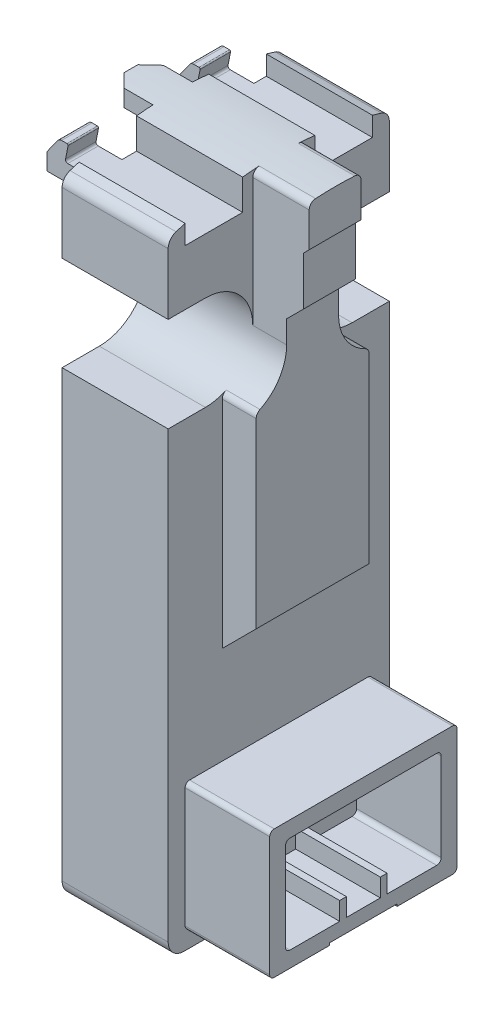
from build123d import *

# Parameters (mm, degrees)
BOSS_EXTRUDE1_DEPTH      = 8.45
SKETCH2_W                = 12
SKETCH2_H                = 30
CUT_EXTRUDE1_DEPTH       = 8.45
CUT_EXTRUDE2_DEPTH       = 8.45
SKETCH4_W                = 0.8
SKETCH4_H                = 1.9
CUT_EXTRUDE3_DEPTH       = 8.45
SKETCH5_W                = 0.8
SKETCH5_H                = 1.9
CUT_EXTRUDE4_DEPTH       = 8.45
BOSS_EXTRUDE2_DEPTH      = 2.5
CUT_EXTRUDE5_DEPTH       = 3
CUT_EXTRUDE5_DEPTH_BACK  = 3
CUT_EXTRUDE6_DEPTH       = 5
CUT_EXTRUDE6_DEPTH_BACK  = 5
SKETCH9_W                = 8.3
SKETCH9_H                = 18.5
CUT_EXTRUDE7_DEPTH       = 3
BOSS_EXTRUDE3_DEPTH      = 3.6
BOSS_EXTRUDE3_DEPTH_BACK = 3.6
SKETCH11_W               = 3
SKETCH11_H               = 4.5
CUT_EXTRUDE8_DEPTH       = 30
BOSS_EXTRUDE4_START      = -1.85
BOSS_EXTRUDE4_DEPTH      = 1.85
CUT_EXTRUDE9_DEPTH       = 30
CUT_EXTRUDE10_DEPTH      = 0.85


with BuildPart() as part:
    # Sketch1 → Boss-Extrude1 (new body)
    with BuildSketch(Plane(origin=(0, 0, 0), x_dir=(0, 0, -1), z_dir=(1, 0, 0))):
        with BuildLine():
            Line((-4.2, 0), (4.2, 0))
            ThreePointArc((4.2, 0), (4.694974747, 0.205025253), (4.9, 0.7))
            Line((4.9, 0.7), (4.9, 27.316294728))
            ThreePointArc((4.9, 27.316294728), (4.803647153, 27.611369254), (4.551724095, 27.792718697))
            ThreePointArc((4.551724095, 27.792718697), (-2.2e-08, 28.5), (-4.551724138, 27.792718684))
            ThreePointArc((-4.551724138, 27.792718684), (-4.803647166, 27.611369236), (-4.9, 27.316294728))
            Line((-4.9, 27.316294728), (-4.9, 0.7))
            ThreePointArc((-4.9, 0.7), (-4.694974747, 0.205025253), (-4.2, 0))
        make_face()
    extrude(amount=BOSS_EXTRUDE1_DEPTH)

    # Sketch2 → Cut-Extrude1 (cut)
    with BuildSketch(Plane(origin=(4.7, 0, 0), x_dir=(0, 0, -1), z_dir=(1, 0, 0))):
        with Locations((0, 14)):
            Rectangle(SKETCH2_W, SKETCH2_H)
        with BuildLine():
            Line((-4.15, 6.25), (-4.15, 0.95))
            ThreePointArc((-4.15, 0.95), (-4.091421356, 0.808578644), (-3.95, 0.75))
            Line((-3.95, 0.75), (3.95, 0.75))
            ThreePointArc((3.95, 0.75), (4.091421356, 0.808578644), (4.15, 0.95))
            Line((4.15, 0.95), (4.15, 6.25))
            ThreePointArc((4.15, 6.25), (4.091421356, 6.391421356), (3.95, 6.45))
            Line((3.95, 6.45), (-3.95, 6.45))
            ThreePointArc((-3.95, 6.45), (-4.091421356, 6.391421356), (-4.15, 6.25))
        make_face(mode=Mode.SUBTRACT)
    extrude(amount=CUT_EXTRUDE1_DEPTH, mode=Mode.SUBTRACT)

    # Sketch3 → Cut-Extrude2 (cut)
    with BuildSketch(Plane(origin=(4.7, 0, 0), x_dir=(0, 0, -1), z_dir=(1, 0, 0))):
        with BuildLine():
            Line((-3.45, 5.55), (-3.45, 1.65))
            ThreePointArc((-3.45, 1.65), (-3.391421356, 1.508578644), (-3.25, 1.45))
            Line((-3.25, 1.45), (-1.05, 1.45))
            Line((-1.05, 1.45), (-1.05, 2.25))
            Line((-1.05, 2.25), (-0.75, 2.25))
            Line((-0.75, 2.25), (-0.75, 1.45))
            Line((-0.75, 1.45), (0.75, 1.45))
            Line((0.75, 1.45), (0.75, 2.25))
            Line((0.75, 2.25), (1.05, 2.25))
            Line((1.05, 2.25), (1.05, 1.45))
            Line((1.05, 1.45), (3.25, 1.45))
            ThreePointArc((3.25, 1.45), (3.391421356, 1.508578644), (3.45, 1.65))
            Line((3.45, 1.65), (3.45, 5.55))
            ThreePointArc((3.45, 5.55), (3.391421356, 5.691421356), (3.25, 5.75))
            Line((3.25, 5.75), (-3.25, 5.75))
            ThreePointArc((-3.25, 5.75), (-3.391421356, 5.691421356), (-3.45, 5.55))
        make_face()
    extrude(amount=CUT_EXTRUDE2_DEPTH, mode=Mode.SUBTRACT)

    # Sketch4 → Cut-Extrude3 (cut)
    with BuildSketch(Plane(origin=(4.7, 0, 0), x_dir=(0, 0, -1), z_dir=(1, 0, 0))):
        with Locations((2, 4.1)):
            Rectangle(SKETCH4_W, SKETCH4_H)
    extrude(amount=-CUT_EXTRUDE3_DEPTH, mode=Mode.SUBTRACT)

    # Sketch5 → Cut-Extrude4 (cut)
    with BuildSketch(Plane(origin=(4.7, 0, 0), x_dir=(0, 0, -1), z_dir=(1, 0, 0))):
        with Locations((-2, 4.1)):
            Rectangle(SKETCH5_W, SKETCH5_H)
    extrude(amount=-CUT_EXTRUDE4_DEPTH, mode=Mode.SUBTRACT)

    # Sketch6 → Boss-Extrude2 (add)
    with BuildSketch(Plane(origin=(4.7, 0, 0), x_dir=(0, 0, -1), z_dir=(1, 0, 0))):
        with BuildLine():
            Line((-2.5, 20.341875815), (-2.5, 10.775))
            Line((-2.5, 10.775), (2.5, 10.775))
            Line((2.5, 10.775), (2.5, 20.341875815))
            ThreePointArc((2.5, 20.341875815), (2.454337374, 20.50097484), (2.33125, 20.611641338))
            ThreePointArc((2.33125, 20.611641338), (1.469638379, 21.38630682), (1.15, 22.5))
            Line((1.15, 22.5), (1.15, 28.175404594))
            ThreePointArc((1.15, 28.175404594), (1.068178929, 28.381312231), (0.867346966, 28.474902645))
            ThreePointArc((0.867346966, 28.474902645), (1.4e-08, 28.5), (-0.867346939, 28.474902647))
            ThreePointArc((-0.867346939, 28.474902647), (-1.068178919, 28.381312241), (-1.15, 28.175404594))
            Line((-1.15, 28.175404594), (-1.15, 22.5))
            ThreePointArc((-1.15, 22.5), (-1.469638379, 21.38630682), (-2.33125, 20.611641338))
            ThreePointArc((-2.33125, 20.611641338), (-2.454337374, 20.50097484), (-2.5, 20.341875815))
        make_face()
    extrude(amount=BOSS_EXTRUDE2_DEPTH)

    # Sketch7 → Cut-Extrude5 (cut, two sides: drawn at the far end of the back side and taken through both)
    with BuildSketch(Plane.XY.offset(-CUT_EXTRUDE5_DEPTH_BACK)):
        Polygon((4.7, 10.775), (12.2, 10.775), (12.2, 30.775), (7.2, 30.775), (7.2, 26.65), (6.95, 26.4), (6.95, 24.25), (6.2, 23.5), (6.2, 12.275), align=None)
    extrude(amount=CUT_EXTRUDE5_DEPTH + CUT_EXTRUDE5_DEPTH_BACK, mode=Mode.SUBTRACT)

    # Sketch8 → Cut-Extrude6 (cut, two sides: drawn at the far end of the back side and taken through both)
    with BuildSketch(Plane(origin=(4.7, 0, 0), x_dir=(0, 0, -1), z_dir=(1, 0, 0)).offset(-CUT_EXTRUDE6_DEPTH_BACK)):
        with BuildLine():
            Line((-7, 20.4), (-3.25, 20.4))
            ThreePointArc((-3.25, 20.4), (-1.15, 22.5), (-3.25, 24.6))
            Line((-3.25, 24.6), (-6, 24.6))
            Line((-6, 24.6), (-6, 30.06))
            Line((-6, 30.06), (-4.15, 30.06))
            Line((-4.15, 30.06), (-4.15, 27.06))
            Line((-4.15, 27.06), (-1.6, 27.06))
            Line((-1.6, 27.06), (-1.6, 29.06))
            Line((-1.6, 29.06), (1.6, 29.06))
            Line((1.6, 29.06), (1.6, 27.06))
            Line((1.6, 27.06), (4.15, 27.06))
            Line((4.15, 27.06), (4.15, 30.06))
            Line((4.15, 30.06), (6, 30.06))
            Line((6, 30.06), (6, 24.6))
            Line((6, 24.6), (3.25, 24.6))
            ThreePointArc((3.25, 24.6), (1.15, 22.5), (3.25, 20.4))
            Line((3.25, 20.4), (7, 20.4))
            Line((7, 20.4), (7, 31.06))
            Line((7, 31.06), (-7, 31.06))
            Line((-7, 31.06), (-7, 20.4))
        make_face()
    extrude(amount=CUT_EXTRUDE6_DEPTH + CUT_EXTRUDE6_DEPTH_BACK, mode=Mode.SUBTRACT)

    # Sketch9 → Cut-Extrude7 (cut)
    with BuildSketch(Plane(origin=(0, 0, 0), x_dir=(0, 0, -1), z_dir=(1, 0, 0))):
        with Locations((0, 10)):
            Rectangle(SKETCH9_W, SKETCH9_H)
    extrude(amount=CUT_EXTRUDE7_DEPTH, mode=Mode.SUBTRACT)

    # Sketch10 → Boss-Extrude3 (add, two sides: drawn at the far end of the back side and taken through both)
    with BuildSketch(Plane.XY.offset(-BOSS_EXTRUDE3_DEPTH_BACK)):
        with BuildLine():
            Line((-1.97, 27.06), (-1.97, 26.31))
            Line((-1.97, 26.31), (0, 26.31))
            Line((0, 26.31), (0, 27.06))
            Line((0, 27.06), (-1.0486903, 27.06))
            ThreePointArc((-1.0486903, 27.06), (-1.125852758, 27.096392178), (-1.146853018, 27.1790809))
            Line((-1.146853018, 27.1790809), (-1.035788259, 27.75045955))
            ThreePointArc((-1.035788259, 27.75045955), (-1.046288389, 27.791803911), (-1.084869618, 27.81))
            Line((-1.084869618, 27.81), (-1.323188014, 27.81))
            ThreePointArc((-1.323188014, 27.81), (-1.413986114, 27.788201305), (-1.484991413, 27.72755705))
            Line((-1.484991413, 27.72755705), (-1.97, 27.06))
        make_face()
    extrude(amount=BOSS_EXTRUDE3_DEPTH + BOSS_EXTRUDE3_DEPTH_BACK)

    # Sketch11 → Cut-Extrude8 (cut)
    with BuildSketch(Plane(origin=(0, 0, 0), x_dir=(1, 0, 0), z_dir=(0, 1, 0))):
        with Locations((-1.5, 0)):
            Rectangle(SKETCH11_W, SKETCH11_H)
    extrude(amount=CUT_EXTRUDE8_DEPTH, mode=Mode.SUBTRACT)

    # Sketch12 → Boss-Extrude4 (add)
    with BuildSketch(Plane(origin=(0, 0, 0), x_dir=(0, 0, -1), z_dir=(1, 0, 0)).offset(BOSS_EXTRUDE4_START)):
        with BuildLine():
            Line((-0.875, 28.474457419), (-0.875, 27.723110595))
            ThreePointArc((-0.875, 27.723110595), (0, 27.75), (0.875, 27.723110595))
            Line((0.875, 27.723110595), (0.875, 28.474457419))
            ThreePointArc((0.875, 28.474457419), (0, 28.5), (-0.875, 28.474457419))
        make_face()
    extrude(amount=BOSS_EXTRUDE4_DEPTH)

    # Sketch13 → Cut-Extrude9 (cut)
    with BuildSketch(Plane(origin=(0, 0, 0), x_dir=(1, 0, 0), z_dir=(0, 1, 0))):
        Polygon((-3.85, -0.875), (-1.284314575, -0.875), (-1.85, -0.309314575), (-1.85, 0.309314575), (-1.284314575, 0.875), (-3.85, 0.875), align=None)
    extrude(amount=CUT_EXTRUDE9_DEPTH, mode=Mode.SUBTRACT)

    # Sketch14 → Cut-Extrude10 (cut)
    with BuildSketch(Plane(origin=(0, 0, 0), x_dir=(1, 0, 0), z_dir=(0, 1, 0))):
        with BuildLine():
            Line((1.1, 1.2), (1.1, -1.2))
            ThreePointArc((1.1, -1.2), (1.187867966, -1.412132034), (1.4, -1.5))
            Line((1.4, -1.5), (9.1, -1.5))
            Line((9.1, -1.5), (9.1, 1.5))
            Line((9.1, 1.5), (1.4, 1.5))
            ThreePointArc((1.4, 1.5), (1.187867966, 1.412132034), (1.1, 1.2))
        make_face()
    extrude(amount=CUT_EXTRUDE10_DEPTH, mode=Mode.SUBTRACT)


solid = part.part
